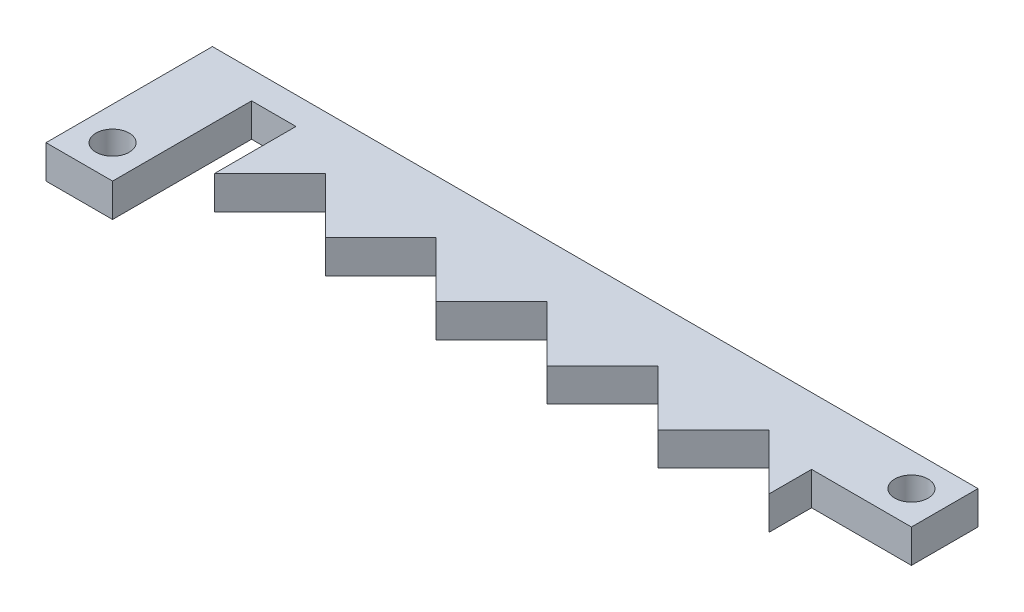
from build123d import *

# Parameters (mm, degrees)
SKETCH1_R           = 1.5
BOSS_EXTRUDE1_DEPTH = 3


with BuildPart() as part:
    # Sketch1 → Boss-Extrude1 (new body)
    with BuildSketch(Plane(origin=(0, 0, 0), x_dir=(1, 0, 0), z_dir=(0, 1, 0))):
        Polygon((0, 42.341154582), (0, 38.341154582), (5, 43.341154582), (10, 38.341154582), (15, 43.341154582), (20, 38.341154582), (25, 43.341154582), (30, 38.341154582), (35, 43.341154582), (40, 38.341154582), (45, 43.341154582), (50, 38.341154582), (50, 42.168762746), (59, 42.168762746), (59, 48.168762746), (58.943690308, 48.168762746), (5, 48.168762746), (-1.848815236, 48.168762746), (-10, 48.168762746), (-10, 33.168762746), (-4, 33.168762746), (-4, 45.696811654), (0, 45.696811654), align=None)
        with Locations((-7, 36.168762746)):
            Circle(SKETCH1_R, mode=Mode.SUBTRACT)
        with Locations((56, 45.168762746)):
            Circle(SKETCH1_R, mode=Mode.SUBTRACT)
    extrude(amount=BOSS_EXTRUDE1_DEPTH)


solid = part.part
